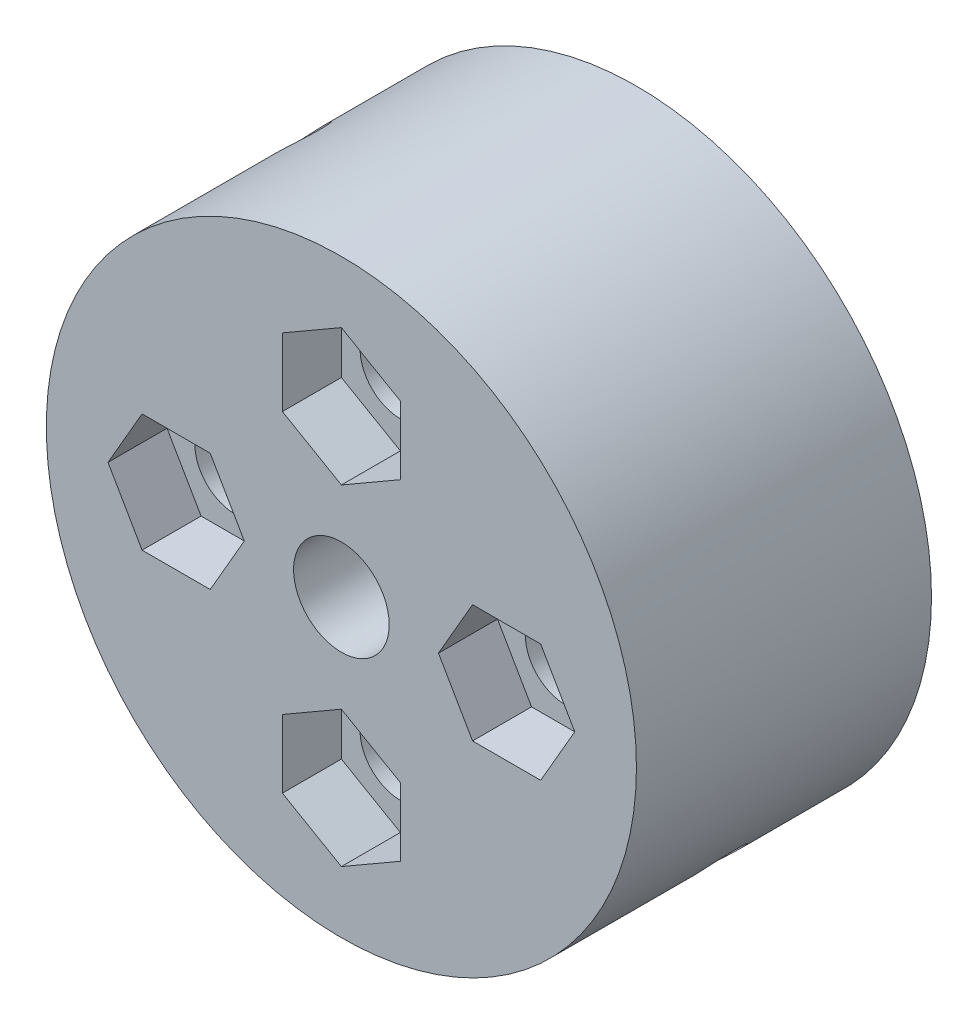
from build123d import *

# Parameters (mm, degrees)
SKETCH1_R               = 12.5
BOSS_EXTRUDE1_DEPTH     = 12.5
CUT_EXTRUDE1_DEPTH      = 2.5
CUT_EXTRUDE2_REACH      = 23.651
SKETCH2_3_R             = 1.71
CIRPATTERN1_COUNT       = 4
CUT_EXTRUDE3_REACH      = 23.651
SKETCH3_R               = 2.025
CUT_EXTRUDE5_DEPTH      = 22.650635095
CUT_EXTRUDE5_DEPTH_BACK = 22.650635095
SKETCH6_R               = 1.08


with BuildPart() as part:
    # Sketch1 → Boss-Extrude1 (new body)
    with BuildSketch(Plane.XY):
        Circle(SKETCH1_R)
    extrude(amount=BOSS_EXTRUDE1_DEPTH)

    # Sketch2 → Cut-Extrude1 (cut)
    with BuildSketch(Plane.XY.offset(12.5)):
        Polygon((2.5, 8.443375673), (0, 9.886751346), (-2.5, 8.443375673), (-2.5, 5.556624327), (0, 4.113248654), (2.5, 5.556624327), align=None)
    cut_extrude1 = extrude(amount=-CUT_EXTRUDE1_DEPTH, mode=Mode.SUBTRACT)

    # Sketch2_3 → Cut-Extrude2 (cut, up to next)
    with BuildSketch(Plane.XY.offset(12.5), mode=Mode.PRIVATE) as cut_extrude2_sk1:
        with Locations((0, 7)):
            Circle(SKETCH2_3_R)
    cut_extrude2_tool1 = extrude(cut_extrude2_sk1.sketch, amount=-CUT_EXTRUDE2_REACH, mode=Mode.PRIVATE) & part.part
    cut_extrude2 = cut_extrude2_tool1.solids().sort_by_distance((0, 7, 12.5))[0]
    add(cut_extrude2, mode=Mode.SUBTRACT)

    # CirPattern1: Cut-Extrude1, Cut-Extrude2 ×4 about axis
    cirpattern1_axis = Axis((0, 0, 12.5), (0, 0, -1))
    add([cut_extrude1.rotate(cirpattern1_axis, i * 360 / CIRPATTERN1_COUNT) for i in range(1, CIRPATTERN1_COUNT)], mode=Mode.SUBTRACT)
    add([cut_extrude2.rotate(cirpattern1_axis, i * 360 / CIRPATTERN1_COUNT) for i in range(1, CIRPATTERN1_COUNT)], mode=Mode.SUBTRACT)

    # Sketch3 → Cut-Extrude3 (cut, up to next)
    with BuildSketch(Plane.XY.offset(12.5), mode=Mode.PRIVATE) as cut_extrude3_sk1:
        Circle(SKETCH3_R)
    cut_extrude3_tool1 = extrude(cut_extrude3_sk1.sketch, amount=-CUT_EXTRUDE3_REACH, mode=Mode.PRIVATE) & part.part
    add(cut_extrude3_tool1.solids().sort_by_distance((0, 0, 12.5))[0], mode=Mode.SUBTRACT)

    # Sketch6 → Cut-Extrude5 (cut, two sides: drawn at the far end of the back side and taken through both)
    with BuildSketch(Plane(origin=(0, 0, 0), x_dir=(0.7071067811865477, 0.7071067811865475, 0), z_dir=(-0.7071067811865475, 0.7071067811865477, 0)).offset(-CUT_EXTRUDE5_DEPTH_BACK)):
        with Locations((0, -5.41)):
            Circle(SKETCH6_R)
    extrude(amount=CUT_EXTRUDE5_DEPTH + CUT_EXTRUDE5_DEPTH_BACK, mode=Mode.SUBTRACT)


solid = part.part
